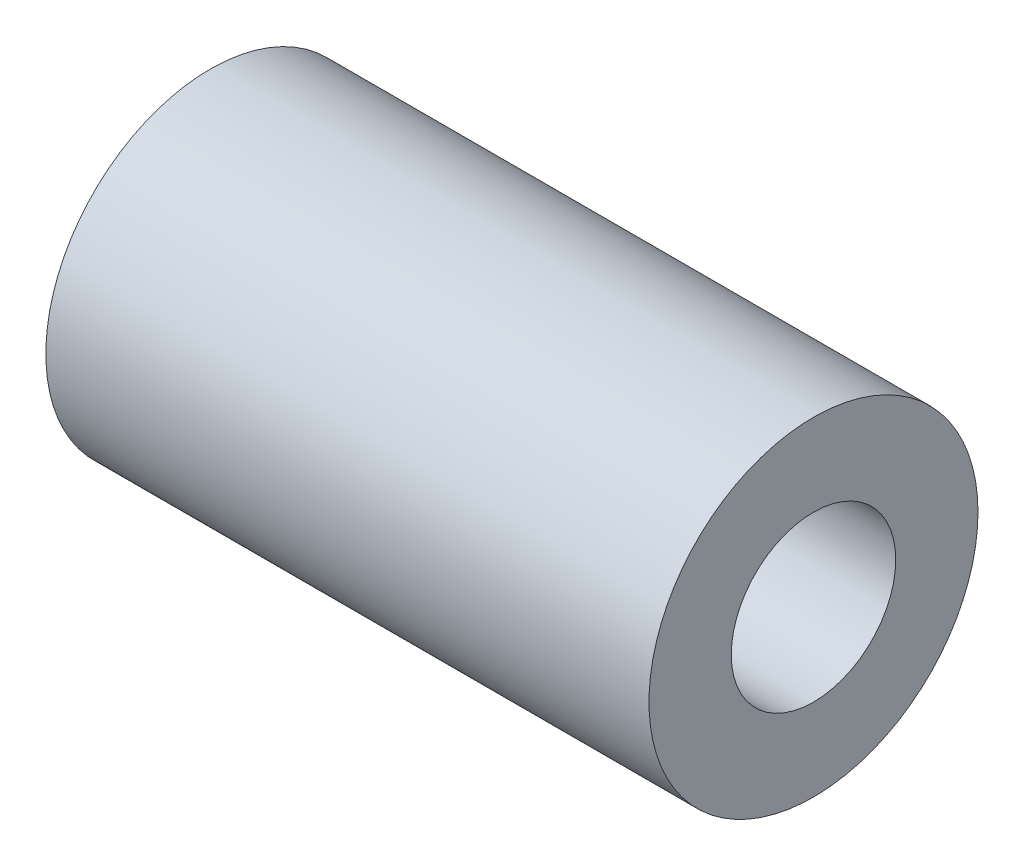
from build123d import *

# Parameters (mm, degrees)
SKETCH1_R           = 9.525
SKETCH1_R_2         = 4.7625
BOSS_EXTRUDE1_DEPTH = 34.925


with BuildPart() as part:
    # Sketch1 → Boss-Extrude1 (new body)
    with BuildSketch(Plane(origin=(0, 0, 0), x_dir=(0, 0, -1), z_dir=(1, 0, 0))):
        Circle(SKETCH1_R)
        Circle(SKETCH1_R_2, mode=Mode.SUBTRACT)
    extrude(amount=BOSS_EXTRUDE1_DEPTH)


solid = part.part
